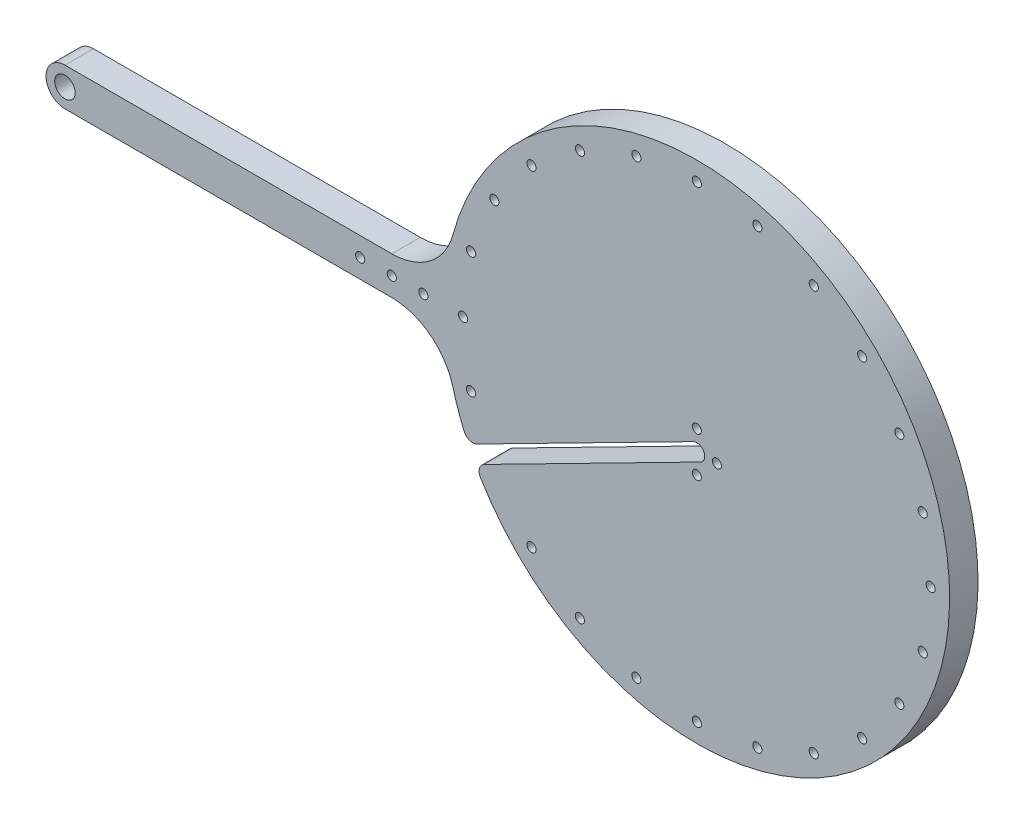
from build123d import *

# Parameters (mm, degrees)
SKETCH1_R           = 1.4225
SKETCH1_R_2         = 1.450000001
SKETCH1_R_3         = 3.250000001
SKETCH1_R_4         = 1.45
BOSS_EXTRUDE2_DEPTH = 9
FILLET1_R           = 3
FILLET2_R           = 3


with BuildPart() as part:
    # Sketch1 → Boss-Extrude2 (new body)
    with BuildSketch(Plane.XY):
        with BuildLine():
            Line((-155.352886895, 10.211716756), (-51.913748531, 10.211716756))
            ThreePointArc((-51.913748531, 10.211716756), (-39.74822347, 6.086224622), (-32.601576204, -4.588283244))
            ThreePointArc((-32.601576204, -4.588283244), (-30.459614432, -11.337865429), (-27.729181359, -17.871592937))
            Line((-27.729181359, -17.871592937), (43.5118499, 18.439086832))
            ThreePointArc((43.5118499, 18.439086832), (46.874483182, 17.346979962), (45.782376313, 13.98434668))
            Line((45.782376313, 13.98434668), (-25.458654946, -22.326333089))
            ThreePointArc((-25.458654946, -22.326333089), (63.046973792, -61.643566474), (124.587919611, 13.13479368))
            ThreePointArc((124.587919611, 13.13479368), (56.661218885, 95.304455124), (-32.601576204, 37.011716756))
            ThreePointArc((-32.601576204, 37.011716756), (-39.74822347, 26.33720889), (-51.913748531, 22.211716756))
            Line((-51.913748531, 22.211716756), (-155.352886895, 22.211716756))
            ThreePointArc((-155.352886895, 22.211716756), (-161.352886895, 16.211716756), (-155.352886895, 10.211716756))
        make_face()
        with Locations((44.647113106, 22.561716756)):
            Circle(SKETCH1_R, mode=Mode.SUBTRACT)
        with Locations((-26.831398039, -2.940892579)):
            Circle(SKETCH1_R_2, mode=Mode.SUBTRACT)
        with Locations((-155.352886895, 16.211716756)):
            Circle(SKETCH1_R_3, mode=Mode.SUBTRACT)
        with Locations((-26.831398039, 35.364326096)):
            Circle(SKETCH1_R_2, mode=Mode.SUBTRACT)
        with Locations((-19.438766774, 53.211716759)):
            Circle(SKETCH1_R_2, mode=Mode.SUBTRACT)
        with Locations((-29.352886893, 16.211716758)):
            Circle(SKETCH1_R_2, mode=Mode.SUBTRACT)
        with Locations((-51.913748531, 16.211716758)):
            Circle(SKETCH1_R_4, mode=Mode.SUBTRACT)
        with Locations((-41.913748531, 16.211716758)):
            Circle(SKETCH1_R_4, mode=Mode.SUBTRACT)
        with Locations((-61.913748531, 16.211716758)):
            Circle(SKETCH1_R_4, mode=Mode.SUBTRACT)
        with Locations((50.997113106, 16.211716756)):
            Circle(SKETCH1_R, mode=Mode.SUBTRACT)
        with Locations((44.647113106, 9.861716756)):
            Circle(SKETCH1_R, mode=Mode.SUBTRACT)
        with Locations((116.125624253, -2.940892579)):
            Circle(SKETCH1_R_2, mode=Mode.SUBTRACT)
        with Locations((108.732992988, -20.788283242)):
            Circle(SKETCH1_R_2, mode=Mode.SUBTRACT)
        with Locations((96.973014915, -36.114185049)):
            Circle(SKETCH1_R_2, mode=Mode.SUBTRACT)
        with Locations((81.647113106, -47.874163121)):
            Circle(SKETCH1_R_2, mode=Mode.SUBTRACT)
        with Locations((63.799722443, -55.266794386)):
            Circle(SKETCH1_R_2, mode=Mode.SUBTRACT)
        with Locations((44.647113106, -57.788283242)):
            Circle(SKETCH1_R_2, mode=Mode.SUBTRACT)
        with Locations((25.494503768, -55.266794386)):
            Circle(SKETCH1_R_2, mode=Mode.SUBTRACT)
        with Locations((7.647113108, -47.874163121)):
            Circle(SKETCH1_R_2, mode=Mode.SUBTRACT)
        with Locations((-7.678788702, -36.114185049)):
            Circle(SKETCH1_R_2, mode=Mode.SUBTRACT)
        with Locations((-7.678788702, 68.537618566)):
            Circle(SKETCH1_R_2, mode=Mode.SUBTRACT)
        with Locations((7.647113108, 80.297596638)):
            Circle(SKETCH1_R_2, mode=Mode.SUBTRACT)
        with Locations((25.494503768, 87.690227903)):
            Circle(SKETCH1_R_2, mode=Mode.SUBTRACT)
        with Locations((44.647113106, 90.211716759)):
            Circle(SKETCH1_R_2, mode=Mode.SUBTRACT)
        with Locations((63.799722443, 87.690227903)):
            Circle(SKETCH1_R_2, mode=Mode.SUBTRACT)
        with Locations((81.647113106, 80.297596638)):
            Circle(SKETCH1_R_2, mode=Mode.SUBTRACT)
        with Locations((96.973014915, 68.537618566)):
            Circle(SKETCH1_R_2, mode=Mode.SUBTRACT)
        with Locations((108.732992988, 53.211716759)):
            Circle(SKETCH1_R_2, mode=Mode.SUBTRACT)
        with Locations((116.125624253, 35.364326096)):
            Circle(SKETCH1_R_2, mode=Mode.SUBTRACT)
        with Locations((118.647113104, 16.211716758)):
            Circle(SKETCH1_R_2, mode=Mode.SUBTRACT)
    extrude(amount=BOSS_EXTRUDE2_DEPTH)

    # Fillet1
    fillet1_edges = [part.edges().sort_by_distance(p)[0] for p in [
        (-27.729181359, -17.871592937, 4.5),
    ]]
    fillet(fillet1_edges, radius=FILLET1_R)

    # Fillet2
    fillet2_edges = [part.edges().sort_by_distance(p)[0] for p in [
        (-25.458654946, -22.326333089, 4.5),
    ]]
    fillet(fillet2_edges, radius=FILLET2_R)


solid = part.part
